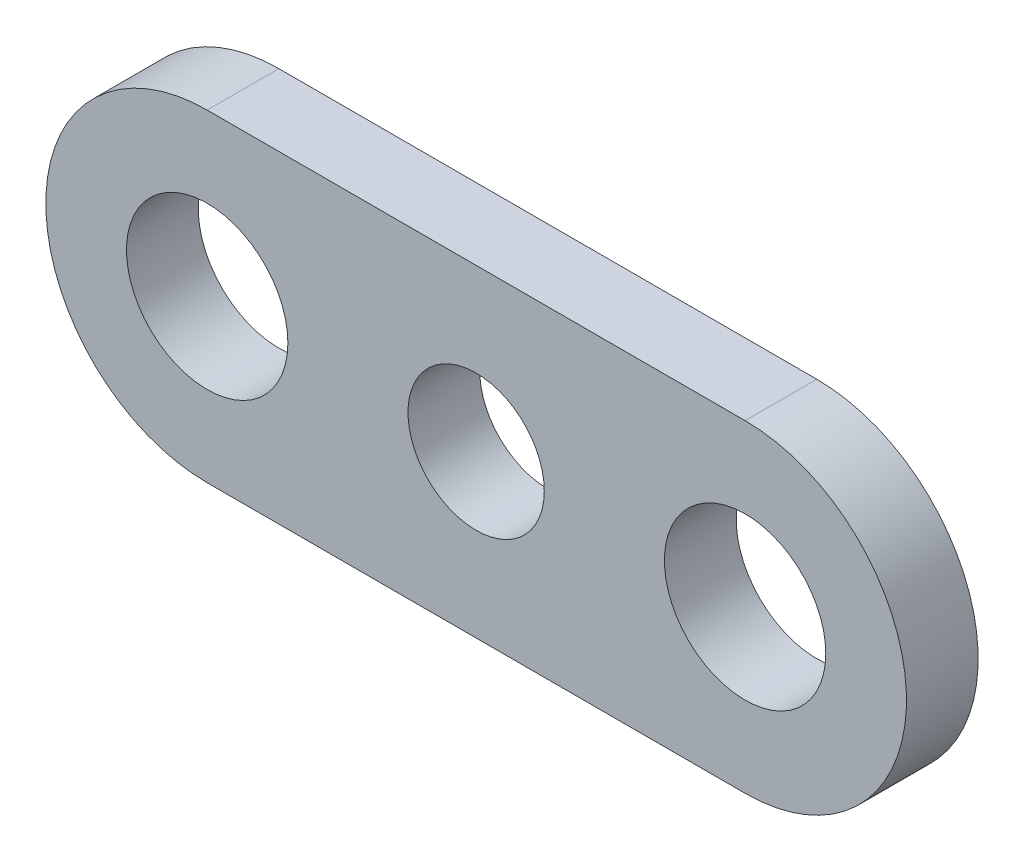
from build123d import *

# Parameters (mm, degrees)
SKETCH1_R            = 1.9
BOSS_EXTRUDE1_DEPTH  = 2
M4_CLEARANCE_HOLE1_D = 4.5


with BuildPart() as part:
    # Sketch1 → Boss-Extrude1 (new body)
    with BuildSketch(Plane.XY):
        with BuildLine():
            Line((-7.5, 4.5), (7.5, 4.5))
            ThreePointArc((7.5, 4.5), (12, 0), (7.5, -4.5))
            Line((7.5, -4.5), (-7.5, -4.5))
            ThreePointArc((-7.5, -4.5), (-12, 0), (-7.5, 4.5))
        make_face()
        Circle(SKETCH1_R, mode=Mode.SUBTRACT)
    extrude(amount=BOSS_EXTRUDE1_DEPTH)

    # M4 Clearance Hole1 (through all)
    with Locations(Plane.XY.offset(2)):
        with Locations((-7.5, 0), (7.5, 0)):
            Hole(M4_CLEARANCE_HOLE1_D / 2)


solid = part.part
